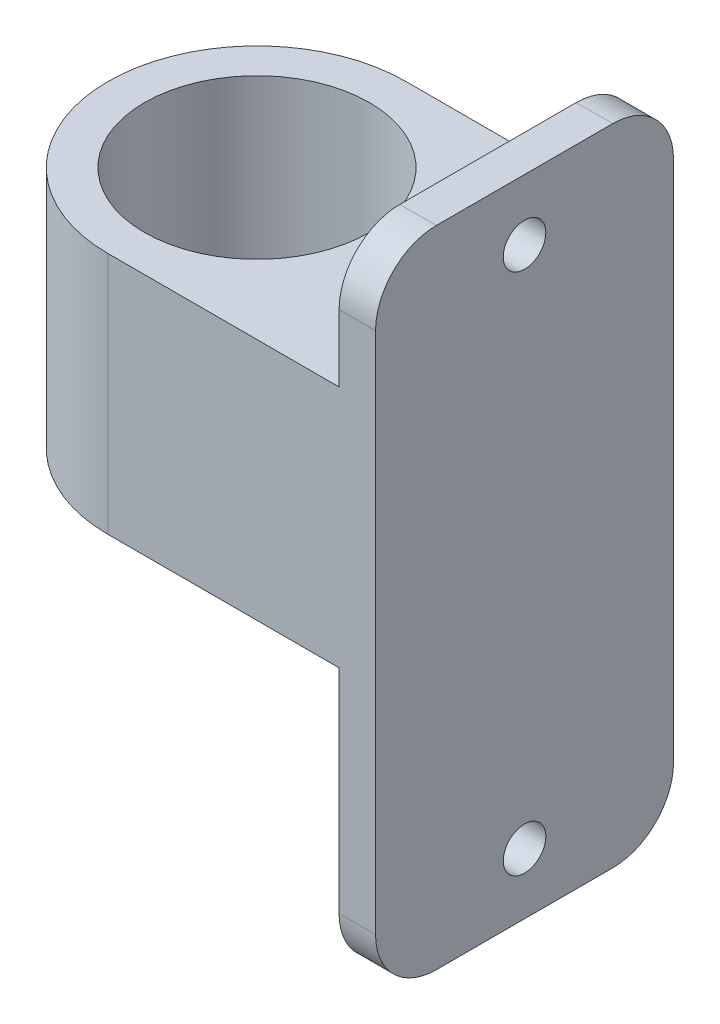
from build123d import *

# Parameters (mm, degrees)
BOSS_EXTRUDE1_DEPTH = 20
SKETCH2_W           = 24.5
SKETCH2_H           = 16.5
SKETCH2_R           = 1.75
BOSS_EXTRUDE2_DEPTH = 3
FILLET1_R           = 5
SKETCH4_R           = 9.25
BOSS_EXTRUDE4_DEPTH = 6
SKETCH3_R           = 9.25
CUT_EXTRUDE1_DEPTH  = 6


with BuildPart() as part:
    # Sketch1 → Boss-Extrude1 (new body)
    with BuildSketch(Plane(origin=(0, 0, 0), x_dir=(1, 0, 0), z_dir=(0, 1, 0))):
        with BuildLine():
            Line((0, 12.25), (0, 9.25))
            ThreePointArc((0, 9.25), (6.540737726, 6.540737726), (9.25, 0))
            ThreePointArc((9.25, 0), (6.540737726, -6.540737726), (0, -9.25))
            Line((0, -9.25), (0, -12.25))
            Line((0, -12.25), (22, -12.25))
            Line((22, -12.25), (22, 12.25))
            Line((22, 12.25), (0, 12.25))
        make_face()
        with BuildLine():
            ThreePointArc((0, -9.25), (-9.25, 0), (0, 9.25))
            Line((0, 9.25), (0, 12.25))
            ThreePointArc((0, 12.25), (-12.25, 0), (0, -12.25))
            Line((0, -12.25), (0, -9.25))
        make_face()
    extrude(amount=BOSS_EXTRUDE1_DEPTH)

    # Sketch2 → Boss-Extrude2 (add)
    with BuildSketch(Plane(origin=(22, 0, 0), x_dir=(0, 0, -1), z_dir=(1, 0, 0))):
        with Locations((0, 28.25)):
            Rectangle(SKETCH2_W, SKETCH2_H)
        with Locations((0, 31.5)):
            Circle(SKETCH2_R, mode=Mode.SUBTRACT)
        with Locations((0, -8.25)):
            Rectangle(SKETCH2_W, SKETCH2_H)
        with Locations(Location((0, -11.5, 0), (0, 0, 180))):
            Circle(SKETCH2_R, mode=Mode.SUBTRACT)
    extrude(amount=-BOSS_EXTRUDE2_DEPTH)

    # Fillet1
    fillet1_edges = [part.edges().sort_by_distance(p)[0] for p in [
        (20.5, 36.5, 12.25),
        (20.5, 36.5, -12.25),
        (20.5, -16.5, -12.25),
        (20.5, -16.5, 12.25),
    ]]
    fillet(fillet1_edges, radius=FILLET1_R)

    # Sketch4 → Boss-Extrude4 (add)
    with BuildSketch(Plane(origin=(0, 20, 0), x_dir=(1, 0, 0), z_dir=(0, 1, 0))):
        with BuildLine():
            Line((0, -12.25), (19, -12.25))
            Line((19, -12.25), (19, 12.25))
            Line((19, 12.25), (0, 12.25))
            ThreePointArc((0, 12.25), (-12.25, 0), (0, -12.25))
        make_face()
        with Locations(Location((0, 0, 0), (0, 0, 270))):
            Circle(SKETCH4_R, mode=Mode.SUBTRACT)
    extrude(amount=BOSS_EXTRUDE4_DEPTH)

    # Sketch3 → Cut-Extrude1 (cut)
    with BuildSketch(Plane.XZ):
        with BuildLine():
            Line((0, -12.25), (19, -12.25))
            Line((19, -12.25), (19, 12.25))
            Line((19, 12.25), (0, 12.25))
            ThreePointArc((0, 12.25), (-12.25, 0), (0, -12.25))
        make_face()
        with Locations(Location((0, 0, 0), (0, 0, 270))):
            Circle(SKETCH3_R, mode=Mode.SUBTRACT)
    extrude(amount=-CUT_EXTRUDE1_DEPTH, mode=Mode.SUBTRACT)


solid = part.part
